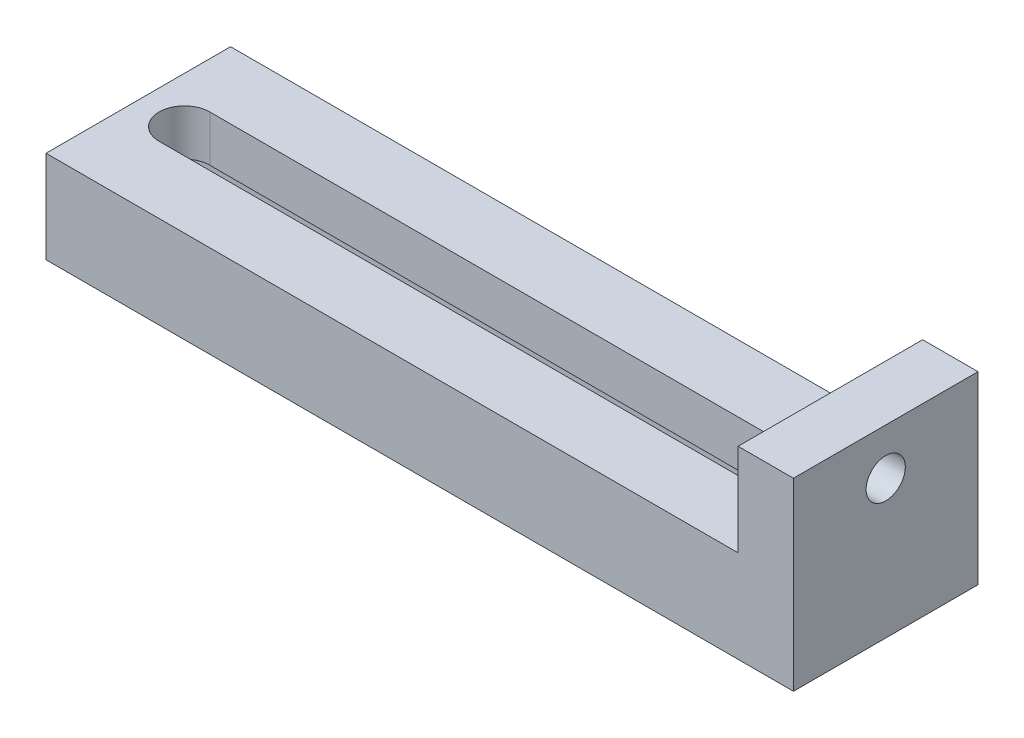
from build123d import *

# Parameters (mm, degrees)
SKETCH_1_W              = 150
SKETCH_1_H              = 40
EXTRUDE_1_DEPTH         = 20
SKETCH_3_W              = 12
SKETCH_3_H              = 40
EXTRUDE_2_DEPTH         = 40
CUT_EXTRUDE_1_DEPTH     = 40
HOLE_WIZARD_M10_1_D     = 8.5
HOLE_WIZARD_M10_1_DEPTH = 24.5
HOLE_WIZARD_M10_1_TIP   = 2.553657631
SKETCH_7_W              = 16
SKETCH_7_H              = 10
CUT_EXTRUDE_2_DEPTH     = 150


with BuildPart() as part:
    # 草图1 → 凸台-拉伸1 (new body)
    with BuildSketch(Plane(origin=(0, 0, 0), x_dir=(1, 0, 0), z_dir=(0, 1, 0))):
        Rectangle(SKETCH_1_W, SKETCH_1_H)
    extrude(amount=EXTRUDE_1_DEPTH)

    # 草图3 → 凸台-拉伸2 (add)
    with BuildSketch(Plane.XZ):
        with Locations((81, 0)):
            Rectangle(SKETCH_3_W, SKETCH_3_H)
    extrude(amount=-EXTRUDE_2_DEPTH)

    # 草图4 → 切除-拉伸1 (cut)
    with BuildSketch(Plane(origin=(0, 20, 0), x_dir=(1, 0, 0), z_dir=(0, 1, 0))):
        with BuildLine():
            Line((-65, 5.5), (65, 5.5))
            ThreePointArc((65, 5.5), (70.5, 0), (65, -5.5))
            Line((65, -5.5), (-65, -5.5))
            ThreePointArc((-65, -5.5), (-70.5, 0), (-65, 5.5))
        make_face()
    extrude(amount=-CUT_EXTRUDE_1_DEPTH, mode=Mode.SUBTRACT)

    # M10 螺纹孔1
    with Locations(Plane(origin=(87, 0, 0), x_dir=(0, 0, -1), z_dir=(1, 0, 0))):
        with Locations((0, 30)):
            Hole(HOLE_WIZARD_M10_1_D / 2, depth=HOLE_WIZARD_M10_1_DEPTH)
            with Locations((0, 0, -(HOLE_WIZARD_M10_1_DEPTH + HOLE_WIZARD_M10_1_TIP / 2))):  # 118° drill point
                Cone(0, HOLE_WIZARD_M10_1_D / 2, HOLE_WIZARD_M10_1_TIP, mode=Mode.SUBTRACT)

    # 草图7 → 切除-拉伸2 (cut)
    with BuildSketch(Plane.ZY.offset(75)):
        with Locations((0, 5)):
            Rectangle(SKETCH_7_W, SKETCH_7_H)
    extrude(amount=-CUT_EXTRUDE_2_DEPTH, mode=Mode.SUBTRACT)


solid = part.part
